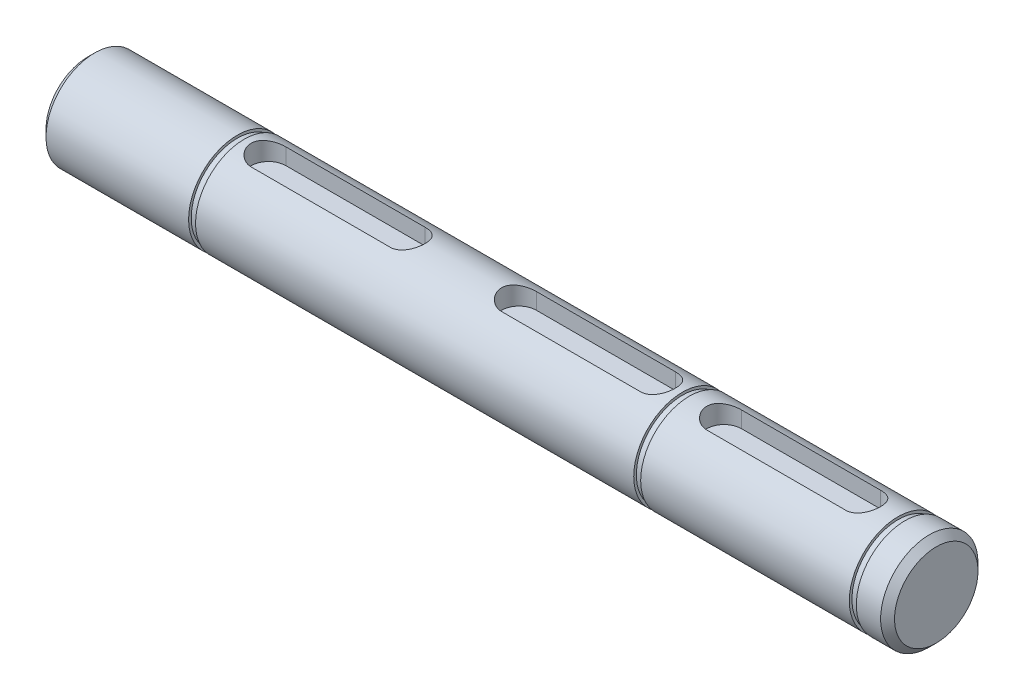
from build123d import *

# Parameters (mm, degrees)
SKETCH1_R           = 7
BOSS_EXTRUDE1_DEPTH = 34
CUT_EXTRUDE1_DEPTH  = 2.8
SKETCH5_R           = 7
BOSS_EXTRUDE3_DEPTH = 20
SKETCH7_R           = 7
BOSS_EXTRUDE4_DEPTH = 34
SKETCH11_W          = 1
SKETCH11_H          = 0.75
CHAMFER1_SIZE       = 1
CUT_EXTRUDE3_DEPTH  = 2.8


with BuildPart() as part:
    # Sketch1 → Boss-Extrude1 (new body, symmetric)
    with BuildSketch(Plane(origin=(0, 0, 0), x_dir=(0, 0, -1), z_dir=(1, 0, 0))):
        Circle(SKETCH1_R)
    extrude(amount=BOSS_EXTRUDE1_DEPTH, both=True)

    # Sketch4 → Cut-Extrude1 (cut)
    with BuildSketch(Plane(origin=(0, 7, 0), x_dir=(1, 0, 0), z_dir=(0, 1, 0))):
        with BuildLine():
            Line((-28, 2.5), (-8, 2.5))
            ThreePointArc((-8, 2.5), (-5.5, 0), (-8, -2.5))
            Line((-8, -2.5), (-28, -2.5))
            ThreePointArc((-28, -2.5), (-30.5, 0), (-28, 2.5))
        make_face()
    cut_extrude1 = extrude(amount=-CUT_EXTRUDE1_DEPTH, mode=Mode.SUBTRACT)

    # Mirror1: Cut-Extrude1 across plane
    add(cut_extrude1.mirror(Plane(origin=(0, 0, 0), x_dir=(0, 0, 1), z_dir=(1, 0, 0))), mode=Mode.SUBTRACT)

    # Sketch5 → Boss-Extrude3 (add)
    with BuildSketch(Plane.ZY.offset(34)):
        Circle(SKETCH5_R)
    extrude(amount=BOSS_EXTRUDE3_DEPTH)

    # Sketch7 → Boss-Extrude4 (add)
    with BuildSketch(Plane(origin=(34, 0, 0), x_dir=(0, 0, -1), z_dir=(1, 0, 0))):
        Circle(SKETCH7_R)
    extrude(amount=BOSS_EXTRUDE4_DEPTH)

    # Sketch11 → Cut-Revolve1 (revolve, cut)
    with BuildSketch(Plane.XY):
        with Locations((63, 7)):
            Rectangle(SKETCH11_W, SKETCH11_H)
        with Locations((32, 7)):
            Rectangle(SKETCH11_W, SKETCH11_H)
        with Locations((-32, 7)):
            Rectangle(SKETCH11_W, SKETCH11_H)
    revolve(axis=Axis((71.5, 0, 0), (-1, 0, 0)), mode=Mode.SUBTRACT)

    # Chamfer1
    chamfer1_edges = [part.edges().sort_by_distance(p)[0] for p in [
        (-54, 0, -7),
        (68, 0, 7),
    ]]
    chamfer(chamfer1_edges, length=CHAMFER1_SIZE)

    # Sketch9 → Cut-Extrude3 (cut)
    with BuildSketch(Plane(origin=(0, 7, 0), x_dir=(1, 0, 0), z_dir=(0, 1, 0))):
        with BuildLine():
            Line((37.5, 2.5), (57.5, 2.5))
            ThreePointArc((57.5, 2.5), (60, 0), (57.5, -2.5))
            Line((57.5, -2.5), (37.5, -2.5))
            ThreePointArc((37.5, -2.5), (35, 0), (37.5, 2.5))
        make_face()
    extrude(amount=-CUT_EXTRUDE3_DEPTH, mode=Mode.SUBTRACT)


solid = part.part
